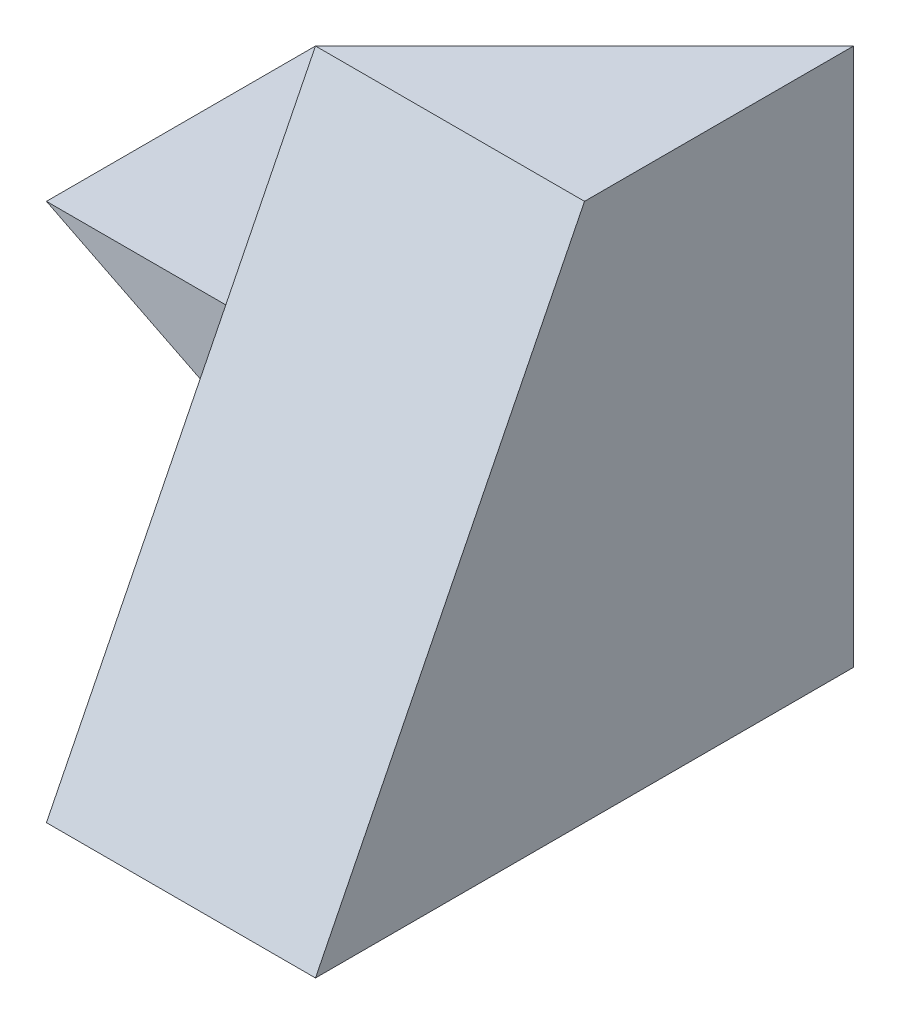
from build123d import *

# Parameters (mm, degrees)
SKETCH1_W           = 40
SKETCH1_H           = 40
BOSS_EXTRUDE1_DEPTH = 40
SKETCH2_W           = 20
SKETCH2_H           = 20
CUT_EXTRUDE1_DEPTH  = 40
CUT_EXTRUDE2_DEPTH  = 40
CUT_EXTRUDE3_DEPTH  = 40
SKETCH5_W           = 20
SKETCH5_H           = 20
CUT_EXTRUDE4_DEPTH  = 40
CUT_EXTRUDE5_DEPTH  = 20
CUT_EXTRUDE13_DEPTH = 20


with BuildPart() as part:
    # Sketch1 → Boss-Extrude1 (new body)
    with BuildSketch(Plane.XY):
        with Locations((20, 20)):
            Rectangle(SKETCH1_W, SKETCH1_H)
    extrude(amount=BOSS_EXTRUDE1_DEPTH)

    # Sketch2 → Cut-Extrude1 (cut)
    with BuildSketch(Plane.XY.offset(40)):
        with Locations((10, 30)):
            Rectangle(SKETCH2_W, SKETCH2_H)
    extrude(amount=-CUT_EXTRUDE1_DEPTH, mode=Mode.SUBTRACT)

    # Sketch3 → Cut-Extrude2 (cut)
    with BuildSketch(Plane.XY.offset(40)):
        Polygon((0, 0), (20, 0), (20, 10), (0, 20), align=None)
    extrude(amount=-CUT_EXTRUDE2_DEPTH, mode=Mode.SUBTRACT)

    # Sketch4 → Cut-Extrude3 (cut)
    with BuildSketch(Plane(origin=(40, 0, 0), x_dir=(0, 0, -1), z_dir=(1, 0, 0))):
        Polygon((-40, 0), (-20, 40), (-40, 40), align=None)
    extrude(amount=-CUT_EXTRUDE3_DEPTH, mode=Mode.SUBTRACT)

    # Sketch5 → Cut-Extrude4 (cut)
    with BuildSketch(Plane.XZ):
        with Locations((10, 30)):
            Rectangle(SKETCH5_W, SKETCH5_H)
    extrude(amount=-CUT_EXTRUDE4_DEPTH, mode=Mode.SUBTRACT)

    # Sketch6 → Cut-Extrude5 (cut)
    with BuildSketch(Plane(origin=(0, 0, 0), x_dir=(-1, 0, 0), z_dir=(0, 0, -1))):
        Polygon((-20, 10), (-40, 0), (-20, 0), align=None)
    extrude(amount=-CUT_EXTRUDE5_DEPTH, mode=Mode.SUBTRACT)

    # Sketch9 → Cut-Extrude13 (cut)
    with BuildSketch(Plane(origin=(0, 40, 0), x_dir=(1, 0, 0), z_dir=(0, 1, 0))):
        Polygon((20, -20), (40, 0), (20, 0), align=None)
    extrude(amount=-CUT_EXTRUDE13_DEPTH, mode=Mode.SUBTRACT)


solid = part.part
